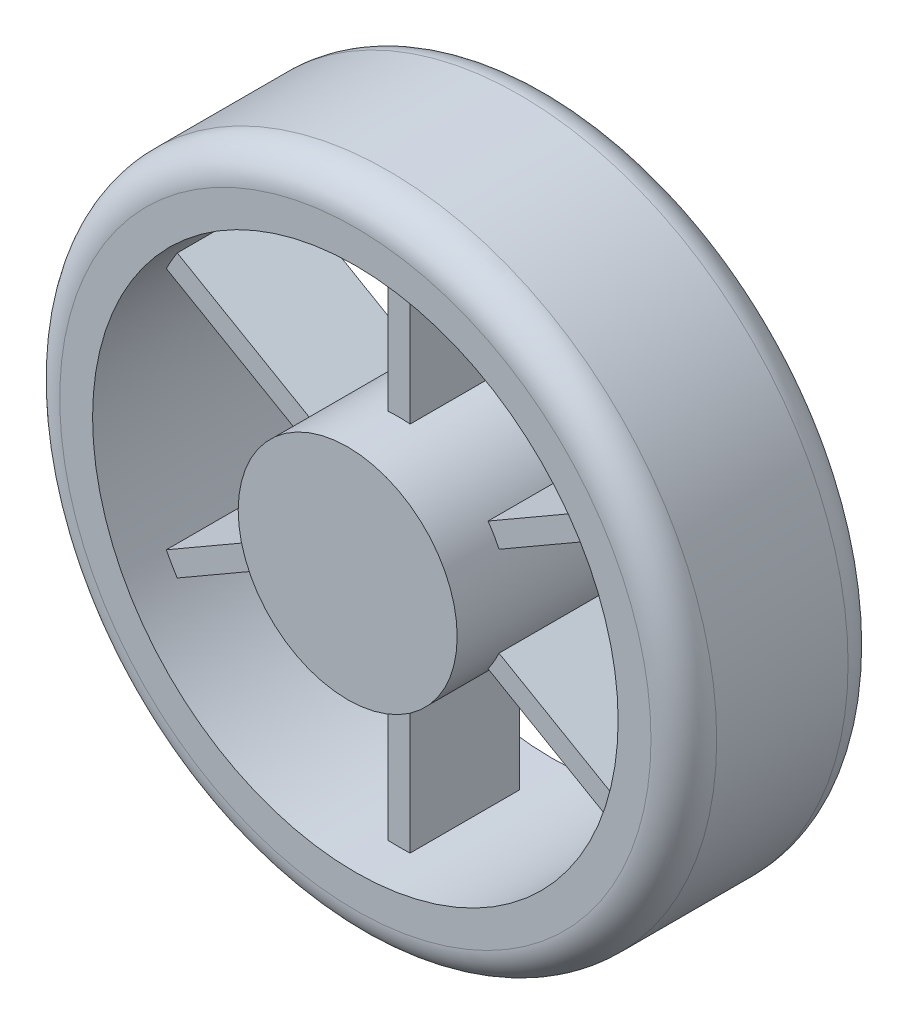
from build123d import *

# Parameters (mm, degrees)
SKETCH1_R           = 50
BOSS_EXTRUDE1_DEPTH = 48.5
SKETCH2_R           = 150
SKETCH2_R_2         = 120
BOSS_EXTRUDE2_DEPTH = 45
BOSS_EXTRUDE3_DEPTH = 25
CIRPATTERN15_COUNT  = 6
FILLET1_R           = 15


with BuildPart() as part:
    # Sketch1 → Boss-Extrude1 (new, symmetric)
    with BuildSketch(Plane.XY):
        Circle(SKETCH1_R)
    extrude(amount=BOSS_EXTRUDE1_DEPTH, both=True)



with BuildPart() as body_2:
    # Sketch2 → Boss-Extrude2 (new, symmetric)
    with BuildSketch(Plane.XY):
        Circle(SKETCH2_R)
        Circle(SKETCH2_R_2, mode=Mode.SUBTRACT)
    extrude(amount=BOSS_EXTRUDE2_DEPTH, both=True)


with BuildPart() as part_1:
    add(part.part)

    add(body_2.part)  # Boss-Extrude3 merges body 2
    # Sketch3 → Boss-Extrude3 (add, symmetric)
    with BuildSketch(Plane.XY):
        with BuildLine():
            Line((-5, 119.895788083), (-5, 49.749371855))
            ThreePointArc((-5, 49.749371855), (0, 50), (5, 49.749371855))
            Line((5, 49.749371855), (5, 119.895788083))
            ThreePointArc((5, 119.895788083), (0, 120), (-5, 119.895788083))
        make_face()
    boss_extrude3 = extrude(amount=BOSS_EXTRUDE3_DEPTH, both=True)

    # CirPattern15: Boss-Extrude3 ×6 about axis
    cirpattern15_axis = Axis((0, 0, -53.35), (0, 0, 1))
    for i in range(1, CIRPATTERN15_COUNT):
        add(boss_extrude3.rotate(cirpattern15_axis, i * 360 / CIRPATTERN15_COUNT))

    # Fillet1
    fillet1_edges = [part_1.edges().sort_by_distance(p)[0] for p in [
        (-150, 0, -45),
        (-150, 0, 45),
    ]]
    fillet(fillet1_edges, radius=FILLET1_R)


solid = part_1.part
